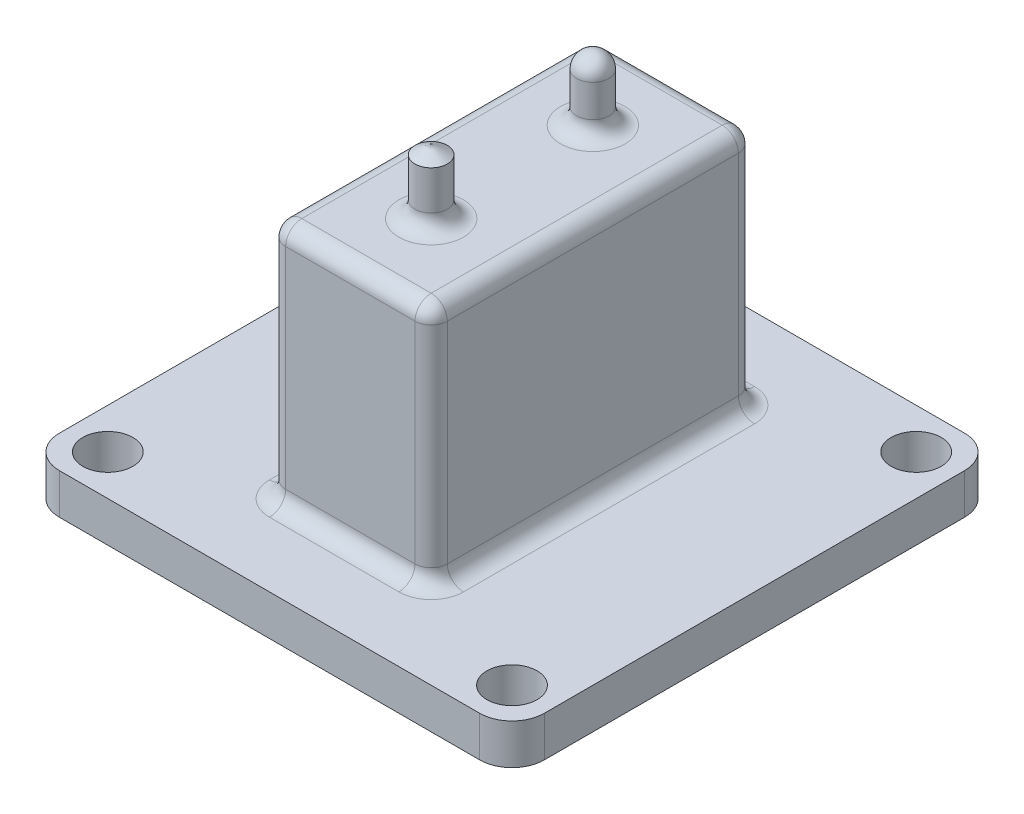
from build123d import *

# Parameters (mm, degrees)
SKETCH1_W           = 60
SKETCH1_H           = 60
SKETCH1_R           = 3.1
BOSS_EXTRUDE1_DEPTH = 5
SKETCH4_W           = 20
SKETCH4_H           = 40
BOSS_EXTRUDE3_DEPTH = 30
SKETCH2_R           = 2
BOSS_EXTRUDE2_DEPTH = 8
FILLET1_R           = 2
FILLET2_R           = 4
FILLET3_R           = 2


with BuildPart() as part:
    # Sketch1 → Boss-Extrude1 (new body)
    with BuildSketch(Plane(origin=(0, 0, 0), x_dir=(1, 0, 0), z_dir=(0, 1, 0))):
        Rectangle(SKETCH1_W, SKETCH1_H)
        with Locations((-25, 25)):
            Circle(SKETCH1_R, mode=Mode.SUBTRACT)
        with Locations((-25, -25)):
            Circle(SKETCH1_R, mode=Mode.SUBTRACT)
        with Locations((25, -25)):
            Circle(SKETCH1_R, mode=Mode.SUBTRACT)
        with Locations((25, 25)):
            Circle(SKETCH1_R, mode=Mode.SUBTRACT)
    extrude(amount=BOSS_EXTRUDE1_DEPTH)

    # Sketch4 → Boss-Extrude3 (add)
    with BuildSketch(Plane(origin=(0, 5, 0), x_dir=(1, 0, 0), z_dir=(0, 1, 0))):
        Rectangle(SKETCH4_W, SKETCH4_H)
    extrude(amount=BOSS_EXTRUDE3_DEPTH)

    # Sketch2 → Boss-Extrude2 (add)
    with BuildSketch(Plane(origin=(0, 35, 0), x_dir=(1, 0, 0), z_dir=(0, 1, 0))):
        with Locations((0, 10)):
            Circle(SKETCH2_R)
        with Locations((0, -10)):
            Circle(SKETCH2_R)
    extrude(amount=BOSS_EXTRUDE2_DEPTH)

    # Fillet1
    fillet1_edges = [part.edges().sort_by_distance(p)[0] for p in [
        (-2, 35, 10),
        (-2, 35, -10),
        (-2, 43, -10),
    ]]
    fillet(fillet1_edges, radius=FILLET1_R)

    # Fillet2
    fillet2_edges = [part.edges().sort_by_distance(p)[0] for p in [
        (30, 2.5, 30),
        (-30, 2.5, 30),
        (-30, 2.5, -30),
        (30, 2.5, -30),
    ]]
    fillet(fillet2_edges, radius=FILLET2_R)

    # Sketch3 → Cut-Revolve3 (revolve, cut)
    with BuildSketch(Plane(origin=(0, 0, 0), x_dir=(0, 0, -1), z_dir=(1, 0, 0))):
        Polygon((-10, 43), (-10, 44), (-12, 44), (-12, 41.845299462), align=None)
    revolve(axis=Axis((0, 43, 10), (0, 1, 0)), mode=Mode.SUBTRACT)

    # Fillet3
    fillet3_edges = [part.edges().sort_by_distance(p)[0] for p in [
        (10, 5, 0),
        (10, 20, 20),
        (0, 5, -20),
        (10, 20, -20),
        (-10, 5, 0),
        (-10, 20, -20),
        (0, 5, 20),
        (-10, 20, 20),
        (10, 35, 0),
        (0, 35, -20),
        (-10, 35, 0),
        (0, 35, 20),
    ]]
    fillet(fillet3_edges, radius=FILLET3_R)


solid = part.part
